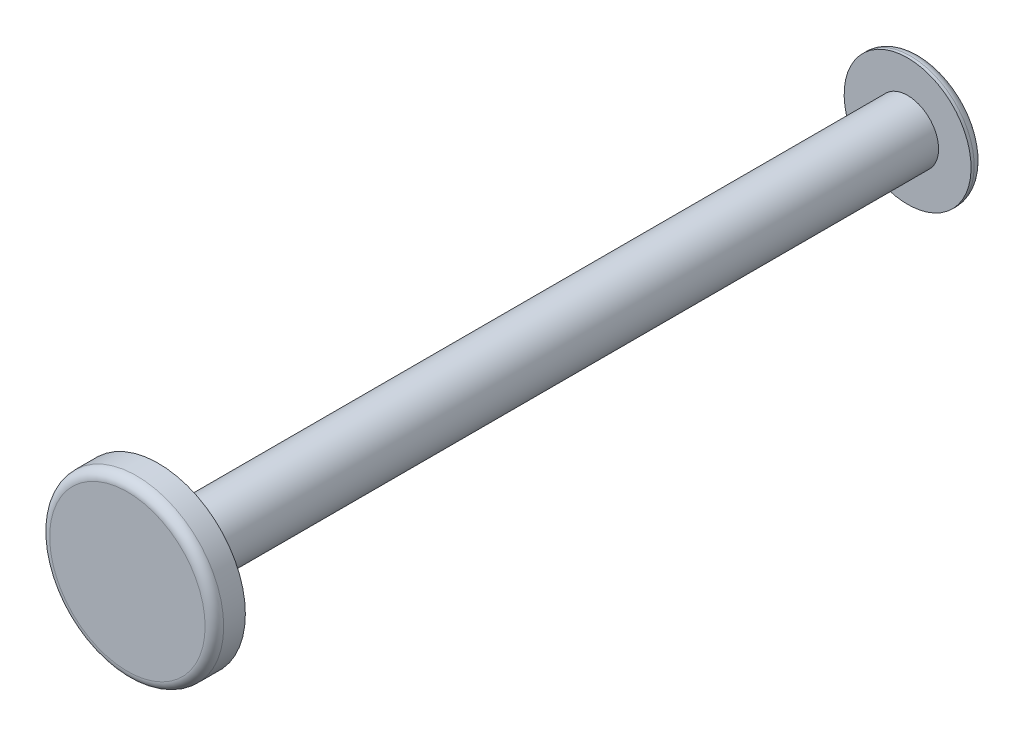
from build123d import *

# Parameters (mm, degrees)
SKETCH1_R           = 1
BASE_EXTRUDE_DEPTH  = 24.2
SKETCH2_R           = 2.81
BOSS_EXTRUDE1_DEPTH = 1
FILLET1_R           = 0.3
SKETCH3_R           = 2.05
BOSS_EXTRUDE2_DEPTH = 0.4
FILLET2_R           = 0.3


with BuildPart() as part:
    # Sketch1 → Base-Extrude (new body)
    with BuildSketch(Plane.XY):
        with Locations((0, 17.5)):
            Circle(SKETCH1_R)
    extrude(amount=-BASE_EXTRUDE_DEPTH)

    # Sketch2 → Boss-Extrude1 (add)
    with BuildSketch(Plane.XY):
        with Locations((0, 17.5)):
            Circle(SKETCH2_R)
    extrude(amount=BOSS_EXTRUDE1_DEPTH)

    # Fillet1
    fillet1_edges = [part.edges().sort_by_distance(p)[0] for p in [
        (-2.81, 17.5, 1),
    ]]
    fillet(fillet1_edges, radius=FILLET1_R)

    # Sketch3 → Boss-Extrude2 (add)
    with BuildSketch(Plane(origin=(0, 0, -24.2), x_dir=(-1, 0, 0), z_dir=(0, 0, -1))):
        with Locations((0, 17.5)):
            Circle(SKETCH3_R)
    extrude(amount=BOSS_EXTRUDE2_DEPTH)

    # Sketch4 → Cut-Revolve1 (revolve, cut)
    with BuildSketch(Plane(origin=(0, 0, -24.6), x_dir=(-1, 0, 0), z_dir=(0, 0, -1))):
        with BuildLine():
            Line((0.918394915, 17.104335014), (-0.918394915, 17.895664986))
            ThreePointArc((-0.918394915, 17.895664986), (-0.395664986, 16.581605085), (0.918394915, 17.104335014))
        make_face()
    revolve(axis=Axis((0.918394915, 17.895664986, -24.6), (-0.918394915, -0.395664986, 0)), mode=Mode.SUBTRACT)

    # Fillet2
    fillet2_edges = [part.edges().sort_by_distance(p)[0] for p in [
        (2.05, 17.5, -24.6),
    ]]
    fillet(fillet2_edges, radius=FILLET2_R)


solid = part.part
